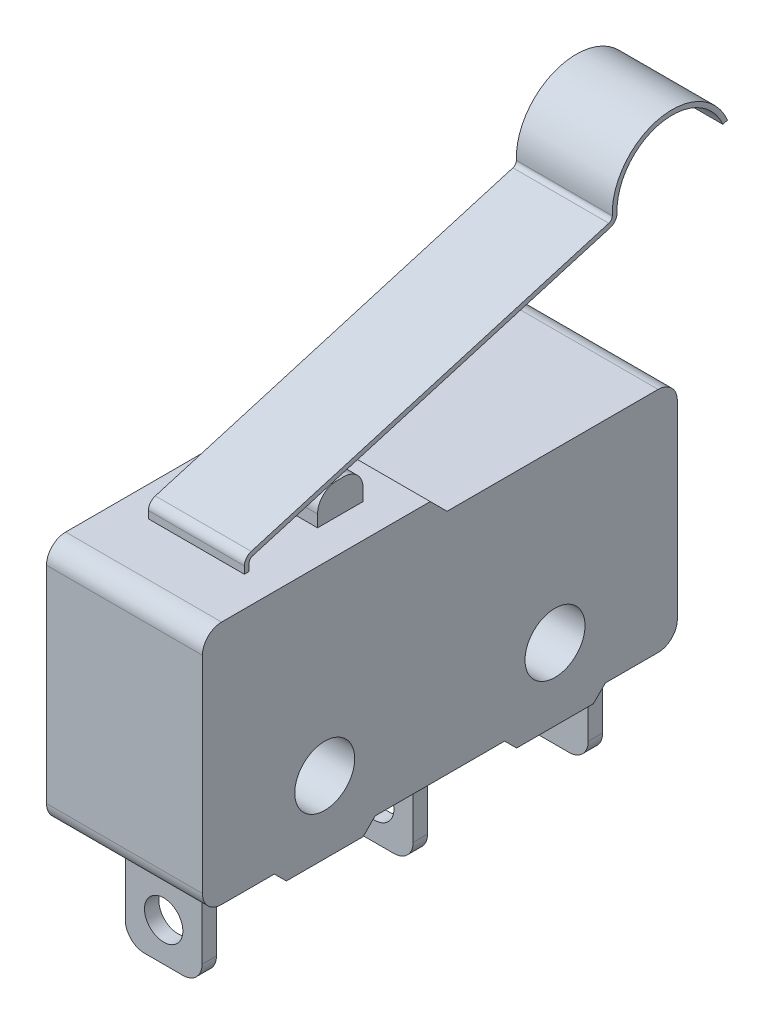
from build123d import *

# Parameters (mm, degrees)
SKETCH_1_R          = 1.25
EXTRUDE_1_DEPTH     = 3.25
SKETCH_4_W          = 0.6
SKETCH_4_H          = 4.2
EXTRUDE_4_DEPTH     = 1.6
FILLET_1_R          = 0.8
SKETCH_2_W          = 3.7
SKETCH_2_H          = 1.9
EXTRUDE_2_DEPTH     = 1.3
FILLET_2_R          = 0.8
EXTRUDE_3_DEPTH     = 2
FILLET_4_R          = 0.2
FILLET_3_R          = 0.4
SKETCH_5_R          = 0.8
CUT_EXTRUDE_1_DEPTH = 16.7


with BuildPart() as part:
    # Эскиз1 → Бобышка-Вытянуть1 (new body, symmetric)
    with BuildSketch(Plane(origin=(0, 0, 0), x_dir=(0, 0, -1), z_dir=(1, 0, 0))):
        Polygon((-9.9, 5.1), (-9.9, -5.1), (-6.9, -5.1), (-6.4, -5.6), (-3.2, -5.6), (-2.7, -5.1), (2.7, -5.1), (3.2, -5.6), (6.4, -5.6), (6.9, -5.1), (9.9, -5.1), (9.9, 4.4), (0.3, 4.4), (-0.4, 5.1), align=None)
        with Locations((-4.8, -2.6)):
            Circle(SKETCH_1_R, mode=Mode.SUBTRACT)
        with Locations((4.8, -2.6)):
            Circle(SKETCH_1_R, mode=Mode.SUBTRACT)
    extrude(amount=EXTRUDE_1_DEPTH, both=True)

    # Эскиз4 → Бобышка-Вытянуть4 (add, symmetric)
    with BuildSketch(Plane(origin=(0, 0, 0), x_dir=(0, 0, -1), z_dir=(1, 0, 0))):
        with Locations((0.834899724, -7.2)):
            Rectangle(SKETCH_4_W, SKETCH_4_H)
        with Locations((-7.965100276, -7.2)):
            Rectangle(SKETCH_4_W, SKETCH_4_H)
        with Locations((8.134899724, -7.2)):
            Rectangle(SKETCH_4_W, SKETCH_4_H)
    extrude(amount=EXTRUDE_4_DEPTH, both=True)

    # Скругление1
    fillet_1_edges = [part.edges().sort_by_distance(p)[0] for p in [
        (0, -5.1, 9.9),
        (0, 5.1, 9.9),
        (0, 4.4, -9.9),
        (0, -5.1, -9.9),
        (-1.6, -9.3, 7.965100276),
        (1.6, -9.3, 7.965100276),
        (-1.6, -9.3, -0.834899724),
        (1.6, -9.3, -0.834899724),
        (-1.6, -9.3, -8.134899724),
        (1.6, -9.3, -8.134899724),
    ]]
    fillet(fillet_1_edges, radius=FILLET_1_R)

    # Эскиз2 → Бобышка-Вытянуть2 (add)
    with BuildSketch(Plane(origin=(0, 5.1, 0), x_dir=(1, 0, 0), z_dir=(0, 1, 0))):
        with Locations((0, -2.75)):
            Rectangle(SKETCH_2_W, SKETCH_2_H)
    extrude(amount=EXTRUDE_2_DEPTH)

    # Скругление2
    fillet_2_edges = [part.edges().sort_by_distance(p)[0] for p in [
        (0, 6.4, 1.8),
        (0, 6.4, 3.7),
    ]]
    fillet(fillet_2_edges, radius=FILLET_2_R)

    # Эскиз3 → Бобышка-Вытянуть3 (add, symmetric)
    with BuildSketch(Plane(origin=(0, 0, 0), x_dir=(0, 0, -1), z_dir=(1, 0, 0))):
        with BuildLine():
            Line((-6.9, 5.1), (-6.9, 5.7))
            Line((-6.9, 5.7), (8.447548782, 10.22247127))
            ThreePointArc((8.447548782, 10.22247127), (10.327160868, 12.885134856), (13.241910115, 11.426726206))
            Line((13.241910115, 11.426726206), (13.048790165, 11.369819437))
            ThreePointArc((13.048790165, 11.369819437), (10.286090587, 12.666664311), (8.668057439, 10.078946335))
            Line((8.668057439, 10.078946335), (-6.7, 5.550431767))
            Line((-6.7, 5.550431767), (-6.7, 5.1))
            Line((-6.7, 5.1), (-6.9, 5.1))
        make_face()
    extrude(amount=EXTRUDE_3_DEPTH, both=True)

    # Скругление4
    fillet_4_edges = [part.edges().sort_by_distance(p)[0] for p in [
        (0, 5.550431767, 6.7),
        (0, 10.22247127, -8.447548782),
    ]]
    fillet(fillet_4_edges, radius=FILLET_4_R)

    # Скругление3
    fillet_3_edges = [part.edges().sort_by_distance(p)[0] for p in [
        (0, 10.078946335, -8.668057439),
        (0, 5.7, 6.9),
    ]]
    fillet(fillet_3_edges, radius=FILLET_3_R)

    # Эскиз5 → Вырез-Вытянуть1 (cut)
    with BuildSketch(Plane.XY.offset(8.265100276)):
        with Locations((0, -7.7)):
            Circle(SKETCH_5_R)
    extrude(amount=-CUT_EXTRUDE_1_DEPTH, mode=Mode.SUBTRACT)


solid = part.part
